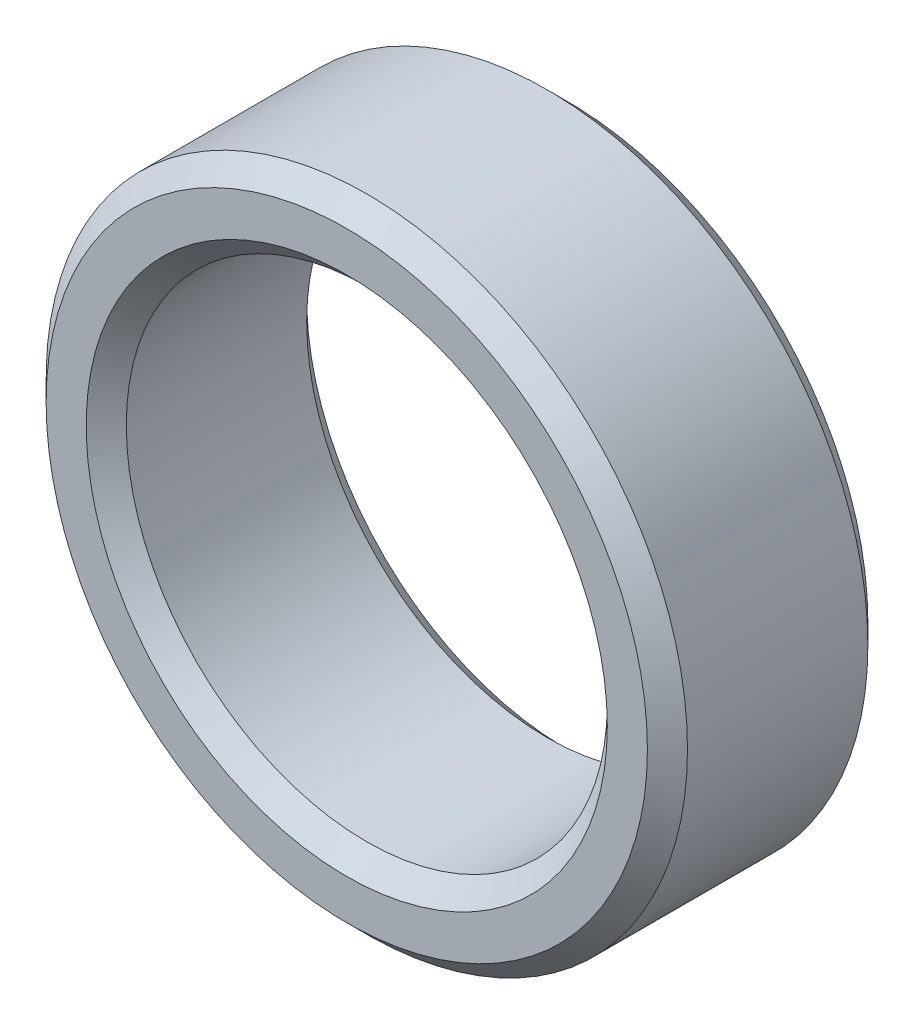
from build123d import *

# Parameters (mm, degrees)
SKETCH1_R           = 8
SKETCH1_R_2         = 6
BOSS_EXTRUDE1_DEPTH = 5.5
CHAMFER1_SIZE       = 0.5


with BuildPart() as part:
    # Sketch1 → Boss-Extrude1 (new body)
    with BuildSketch(Plane.XY):
        Circle(SKETCH1_R)
        Circle(SKETCH1_R_2, mode=Mode.SUBTRACT)
    extrude(amount=BOSS_EXTRUDE1_DEPTH)

    # Chamfer1
    chamfer1_edges = [part.edges().sort_by_distance(p)[0] for p in [
        (-8, 0, 0),
        (-8, 0, 5.5),
        (-6, 0, 0),
        (-6, 0, 5.5),
    ]]
    chamfer(chamfer1_edges, length=CHAMFER1_SIZE)


solid = part.part
